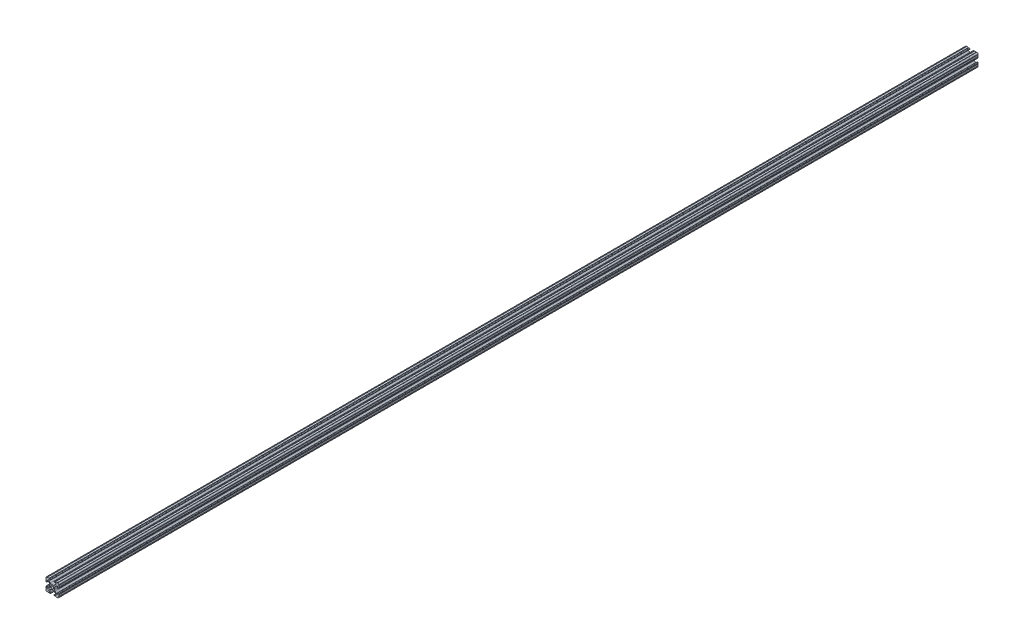
from build123d import *

# Parameters (mm, degrees)
SKETCH1_R           = 2.6035
BOSS_EXTRUDE1_DEPTH = 914.4


with BuildPart() as part:
    # Sketch1 → Boss-Extrude1 (new body, symmetric)
    with BuildSketch(Plane.XY):
        with BuildLine():
            Line((-7.179650497, -8.645192506), (-3.952270251, -5.423690499))
            ThreePointArc((-3.952270251, -5.423690499), (-2.922936451, -4.736929036), (-1.709253557, -4.4958))
            Line((-1.709253557, -4.4958), (1.709253557, -4.4958))
            ThreePointArc((1.709253557, -4.4958), (2.922936451, -4.736929036), (3.952270251, -5.423690499))
            Line((3.952270251, -5.423690499), (7.179650497, -8.645192506))
            ThreePointArc((7.179650497, -8.645192506), (7.41473083, -9.822813117), (6.416408329, -10.4902))
            Line((6.416408329, -10.4902), (4.287512407, -10.4902))
            ThreePointArc((4.287512407, -10.4902), (3.54574862, -10.79744862), (3.2385, -11.539212407))
            Line((3.2385, -11.539212407), (3.2385, -11.650987593))
            ThreePointArc((3.2385, -11.650987593), (3.54574862, -12.39275138), (4.287512407, -12.7))
            Line((4.287512407, -12.7), (5.317126718, -12.7))
            ThreePointArc((5.317126718, -12.7), (5.825126718, -12.192), (6.333126718, -12.7))
            Line((6.333126718, -12.7), (9.550443118, -12.7))
            ThreePointArc((9.550443118, -12.7), (10.058366869, -12.192000006), (10.566443095, -12.699847501))
            ThreePointArc((10.566443095, -12.699847501), (12.082537762, -12.08250727), (12.699846982, -10.566399977))
            ThreePointArc((12.699846982, -10.566399977), (12.192000006, -10.058323491), (12.7, -9.5504))
            Line((12.7, -9.5504), (12.7, -6.3330836))
            ThreePointArc((12.7, -6.3330836), (12.192, -5.8250836), (12.7, -5.3170836))
            Line((12.7, -5.3170836), (12.7, -4.287469289))
            ThreePointArc((12.7, -4.287469289), (12.39275138, -3.545705502), (11.650987593, -3.238456882))
            Line((11.650987593, -3.238456882), (11.539212407, -3.238456882))
            ThreePointArc((11.539212407, -3.238456882), (10.79744862, -3.545705502), (10.4902, -4.287469289))
            Line((10.4902, -4.287469289), (10.4902, -6.402089023))
            ThreePointArc((10.4902, -6.402089023), (9.856505071, -7.351067942), (8.737131347, -7.129408934))
            Line((8.737131347, -7.129408934), (5.441005833, -3.840816462))
            ThreePointArc((5.441005833, -3.840816462), (4.750877967, -2.809883091), (4.5085, -1.593185507))
            Line((4.5085, -1.593185507), (4.5085, 1.593185507))
            ThreePointArc((4.5085, 1.593185507), (4.750877967, 2.809883091), (5.441005833, 3.840816462))
            Line((5.441005833, 3.840816462), (8.737131347, 7.129408934))
            ThreePointArc((8.737131347, 7.129408934), (9.856505071, 7.351067942), (10.4902, 6.402089023))
            Line((10.4902, 6.402089023), (10.4902, 4.287469289))
            ThreePointArc((10.4902, 4.287469289), (10.79744862, 3.545705502), (11.539212407, 3.238456882))
            Line((11.539212407, 3.238456882), (11.650987593, 3.238456882))
            ThreePointArc((11.650987593, 3.238456882), (12.39275138, 3.545705502), (12.7, 4.287469289))
            Line((12.7, 4.287469289), (12.7, 5.3170836))
            ThreePointArc((12.7, 5.3170836), (12.192, 5.8250836), (12.7, 6.3330836))
            Line((12.7, 6.3330836), (12.7, 9.5504))
            ThreePointArc((12.7, 9.5504), (12.192000006, 10.058323491), (12.699846982, 10.566399977))
            ThreePointArc((12.699846982, 10.566399977), (12.082537762, 12.08250727), (10.566443095, 12.699847501))
            ThreePointArc((10.566443095, 12.699847501), (10.058366869, 12.192000006), (9.550443118, 12.7))
            Line((9.550443118, 12.7), (6.333126718, 12.7))
            ThreePointArc((6.333126718, 12.7), (5.825126718, 12.192), (5.317126718, 12.7))
            Line((5.317126718, 12.7), (4.287512407, 12.7))
            ThreePointArc((4.287512407, 12.7), (3.54574862, 12.39275138), (3.2385, 11.650987593))
            Line((3.2385, 11.650987593), (3.2385, 11.539212407))
            ThreePointArc((3.2385, 11.539212407), (3.54574862, 10.79744862), (4.287512407, 10.4902))
            Line((4.287512407, 10.4902), (6.476788598, 10.4902))
            ThreePointArc((6.476788598, 10.4902), (7.432222385, 9.85140422), (7.207036008, 8.724370562))
            Line((7.207036008, 8.724370562), (3.898272566, 5.423169045))
            ThreePointArc((3.898272566, 5.423169045), (2.869120213, 4.736787962), (1.655778399, 4.4958))
            Line((1.655778399, 4.4958), (-1.655778399, 4.4958))
            ThreePointArc((-1.655778399, 4.4958), (-2.869120213, 4.736787962), (-3.898272566, 5.423169045))
            Line((-3.898272566, 5.423169045), (-7.207036008, 8.724370562))
            ThreePointArc((-7.207036008, 8.724370562), (-7.432222385, 9.85140422), (-6.476788598, 10.4902))
            Line((-6.476788598, 10.4902), (-4.287512407, 10.4902))
            ThreePointArc((-4.287512407, 10.4902), (-3.54574862, 10.79744862), (-3.2385, 11.539212407))
            Line((-3.2385, 11.539212407), (-3.2385, 11.650987593))
            ThreePointArc((-3.2385, 11.650987593), (-3.54574862, 12.39275138), (-4.287512407, 12.7))
            Line((-4.287512407, 12.7), (-5.317126718, 12.7))
            ThreePointArc((-5.317126718, 12.7), (-5.825126718, 12.192), (-6.333126718, 12.7))
            Line((-6.333126718, 12.7), (-9.550443118, 12.7))
            ThreePointArc((-9.550443118, 12.7), (-10.058366869, 12.192000006), (-10.566443095, 12.699847501))
            ThreePointArc((-10.566443095, 12.699847501), (-12.082537762, 12.08250727), (-12.699846982, 10.566399977))
            ThreePointArc((-12.699846982, 10.566399977), (-12.192000006, 10.058323491), (-12.7, 9.5504))
            Line((-12.7, 9.5504), (-12.7, 6.3330836))
            ThreePointArc((-12.7, 6.3330836), (-12.192, 5.8250836), (-12.7, 5.3170836))
            Line((-12.7, 5.3170836), (-12.7, 4.287469289))
            ThreePointArc((-12.7, 4.287469289), (-12.39275138, 3.545705502), (-11.650987593, 3.238456882))
            Line((-11.650987593, 3.238456882), (-11.539212407, 3.238456882))
            ThreePointArc((-11.539212407, 3.238456882), (-10.79744862, 3.545705502), (-10.4902, 4.287469289))
            Line((-10.4902, 4.287469289), (-10.4902, 6.402089023))
            ThreePointArc((-10.4902, 6.402089023), (-9.856505071, 7.351067942), (-8.737131347, 7.129408934))
            Line((-8.737131347, 7.129408934), (-5.441005833, 3.840816462))
            ThreePointArc((-5.441005833, 3.840816462), (-4.750877967, 2.809883091), (-4.5085, 1.593185507))
            Line((-4.5085, 1.593185507), (-4.5085, -1.593185507))
            ThreePointArc((-4.5085, -1.593185507), (-4.750877967, -2.809883091), (-5.441005833, -3.840816462))
            Line((-5.441005833, -3.840816462), (-8.737131347, -7.129408934))
            ThreePointArc((-8.737131347, -7.129408934), (-9.856505071, -7.351067942), (-10.4902, -6.402089023))
            Line((-10.4902, -6.402089023), (-10.4902, -4.287469289))
            ThreePointArc((-10.4902, -4.287469289), (-10.79744862, -3.545705502), (-11.539212407, -3.238456882))
            Line((-11.539212407, -3.238456882), (-11.650987593, -3.238456882))
            ThreePointArc((-11.650987593, -3.238456882), (-12.39275138, -3.545705502), (-12.7, -4.287469289))
            Line((-12.7, -4.287469289), (-12.7, -5.3170836))
            ThreePointArc((-12.7, -5.3170836), (-12.192, -5.8250836), (-12.7, -6.3330836))
            Line((-12.7, -6.3330836), (-12.7, -9.5504))
            ThreePointArc((-12.7, -9.5504), (-12.192000006, -10.058323491), (-12.699846982, -10.566399977))
            ThreePointArc((-12.699846982, -10.566399977), (-12.082537762, -12.08250727), (-10.566443095, -12.699847501))
            ThreePointArc((-10.566443095, -12.699847501), (-10.058366869, -12.192000006), (-9.550443118, -12.7))
            Line((-9.550443118, -12.7), (-6.333126718, -12.7))
            ThreePointArc((-6.333126718, -12.7), (-5.825126718, -12.192), (-5.317126718, -12.7))
            Line((-5.317126718, -12.7), (-4.287512407, -12.7))
            ThreePointArc((-4.287512407, -12.7), (-3.54574862, -12.39275138), (-3.2385, -11.650987593))
            Line((-3.2385, -11.650987593), (-3.2385, -11.539212407))
            ThreePointArc((-3.2385, -11.539212407), (-3.54574862, -10.79744862), (-4.287512407, -10.4902))
            Line((-4.287512407, -10.4902), (-6.416408329, -10.4902))
            ThreePointArc((-6.416408329, -10.4902), (-7.41473083, -9.822813117), (-7.179650497, -8.645192506))
        make_face()
        Circle(SKETCH1_R, mode=Mode.SUBTRACT)
    extrude(amount=BOSS_EXTRUDE1_DEPTH, both=True)


solid = part.part
